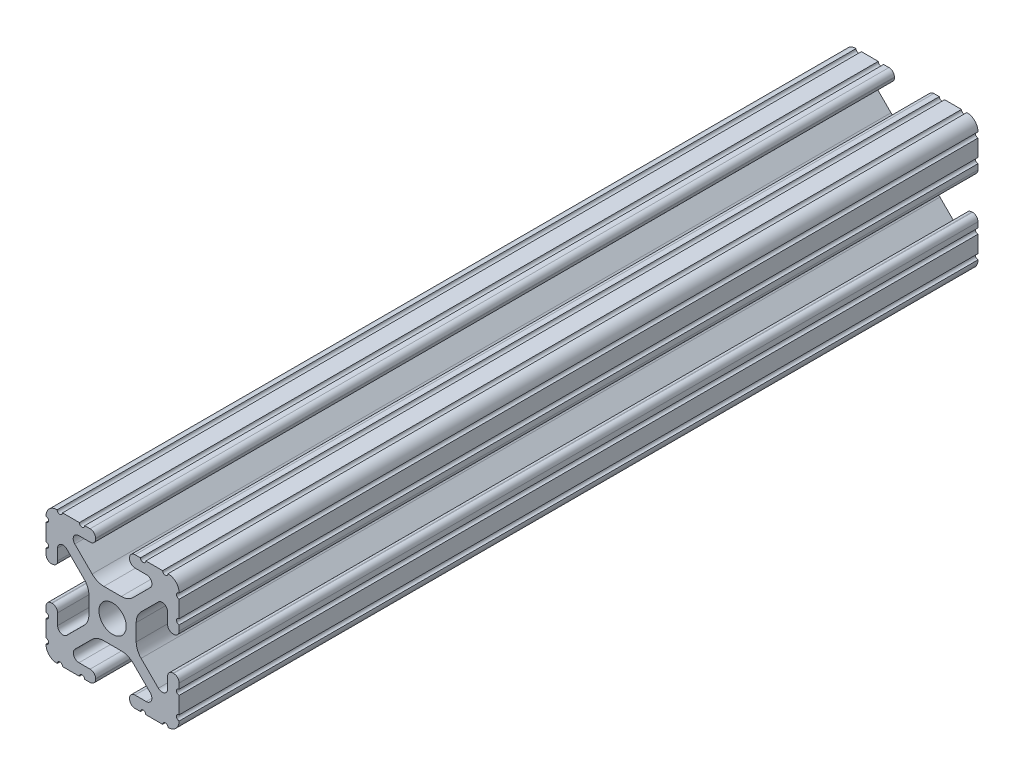
from build123d import *

# Parameters (mm, degrees)
SKETCH1_R           = 2.6035
BOSS_EXTRUDE1_DEPTH = 76.2


with BuildPart() as part:
    # Sketch1 → Boss-Extrude1 (new body, symmetric)
    with BuildSketch(Plane.XY):
        with BuildLine():
            Line((-7.179650497, -8.645192506), (-3.952270251, -5.423690499))
            ThreePointArc((-3.952270251, -5.423690499), (-2.922936451, -4.736929036), (-1.709253557, -4.4958))
            Line((-1.709253557, -4.4958), (1.709253557, -4.4958))
            ThreePointArc((1.709253557, -4.4958), (2.922936451, -4.736929036), (3.952270251, -5.423690499))
            Line((3.952270251, -5.423690499), (7.179650497, -8.645192506))
            ThreePointArc((7.179650497, -8.645192506), (7.41473083, -9.822813117), (6.416408329, -10.4902))
            Line((6.416408329, -10.4902), (4.287512407, -10.4902))
            ThreePointArc((4.287512407, -10.4902), (3.54574862, -10.79744862), (3.2385, -11.539212407))
            Line((3.2385, -11.539212407), (3.2385, -11.650987593))
            ThreePointArc((3.2385, -11.650987593), (3.54574862, -12.39275138), (4.287512407, -12.7))
            Line((4.287512407, -12.7), (5.317126718, -12.7))
            ThreePointArc((5.317126718, -12.7), (5.825126718, -12.192), (6.333126718, -12.7))
            Line((6.333126718, -12.7), (9.550443118, -12.7))
            ThreePointArc((9.550443118, -12.7), (10.058366869, -12.192000006), (10.566443095, -12.699847501))
            ThreePointArc((10.566443095, -12.699847501), (12.082537762, -12.08250727), (12.699846982, -10.566399977))
            ThreePointArc((12.699846982, -10.566399977), (12.192000006, -10.058323491), (12.7, -9.5504))
            Line((12.7, -9.5504), (12.7, -6.3330836))
            ThreePointArc((12.7, -6.3330836), (12.192, -5.8250836), (12.7, -5.3170836))
            Line((12.7, -5.3170836), (12.7, -4.287469289))
            ThreePointArc((12.7, -4.287469289), (12.39275138, -3.545705502), (11.650987593, -3.238456882))
            Line((11.650987593, -3.238456882), (11.539212407, -3.238456882))
            ThreePointArc((11.539212407, -3.238456882), (10.79744862, -3.545705502), (10.4902, -4.287469289))
            Line((10.4902, -4.287469289), (10.4902, -6.402089023))
            ThreePointArc((10.4902, -6.402089023), (9.856505071, -7.351067942), (8.737131347, -7.129408934))
            Line((8.737131347, -7.129408934), (5.441005833, -3.840816462))
            ThreePointArc((5.441005833, -3.840816462), (4.750877967, -2.809883091), (4.5085, -1.593185507))
            Line((4.5085, -1.593185507), (4.5085, 1.593185507))
            ThreePointArc((4.5085, 1.593185507), (4.750877967, 2.809883091), (5.441005833, 3.840816462))
            Line((5.441005833, 3.840816462), (8.737131347, 7.129408934))
            ThreePointArc((8.737131347, 7.129408934), (9.856505071, 7.351067942), (10.4902, 6.402089023))
            Line((10.4902, 6.402089023), (10.4902, 4.287469289))
            ThreePointArc((10.4902, 4.287469289), (10.79744862, 3.545705502), (11.539212407, 3.238456882))
            Line((11.539212407, 3.238456882), (11.650987593, 3.238456882))
            ThreePointArc((11.650987593, 3.238456882), (12.39275138, 3.545705502), (12.7, 4.287469289))
            Line((12.7, 4.287469289), (12.7, 5.3170836))
            ThreePointArc((12.7, 5.3170836), (12.192, 5.8250836), (12.7, 6.3330836))
            Line((12.7, 6.3330836), (12.7, 9.5504))
            ThreePointArc((12.7, 9.5504), (12.192000006, 10.058323491), (12.699846982, 10.566399977))
            ThreePointArc((12.699846982, 10.566399977), (12.082537762, 12.08250727), (10.566443095, 12.699847501))
            ThreePointArc((10.566443095, 12.699847501), (10.058366869, 12.192000006), (9.550443118, 12.7))
            Line((9.550443118, 12.7), (6.333126718, 12.7))
            ThreePointArc((6.333126718, 12.7), (5.825126718, 12.192), (5.317126718, 12.7))
            Line((5.317126718, 12.7), (4.287512407, 12.7))
            ThreePointArc((4.287512407, 12.7), (3.54574862, 12.39275138), (3.2385, 11.650987593))
            Line((3.2385, 11.650987593), (3.2385, 11.539212407))
            ThreePointArc((3.2385, 11.539212407), (3.54574862, 10.79744862), (4.287512407, 10.4902))
            Line((4.287512407, 10.4902), (6.476788598, 10.4902))
            ThreePointArc((6.476788598, 10.4902), (7.432222385, 9.85140422), (7.207036008, 8.724370562))
            Line((7.207036008, 8.724370562), (3.898272566, 5.423169045))
            ThreePointArc((3.898272566, 5.423169045), (2.869120213, 4.736787962), (1.655778399, 4.4958))
            Line((1.655778399, 4.4958), (-1.655778399, 4.4958))
            ThreePointArc((-1.655778399, 4.4958), (-2.869120213, 4.736787962), (-3.898272566, 5.423169045))
            Line((-3.898272566, 5.423169045), (-7.207036008, 8.724370562))
            ThreePointArc((-7.207036008, 8.724370562), (-7.432222385, 9.85140422), (-6.476788598, 10.4902))
            Line((-6.476788598, 10.4902), (-4.287512407, 10.4902))
            ThreePointArc((-4.287512407, 10.4902), (-3.54574862, 10.79744862), (-3.2385, 11.539212407))
            Line((-3.2385, 11.539212407), (-3.2385, 11.650987593))
            ThreePointArc((-3.2385, 11.650987593), (-3.54574862, 12.39275138), (-4.287512407, 12.7))
            Line((-4.287512407, 12.7), (-5.317126718, 12.7))
            ThreePointArc((-5.317126718, 12.7), (-5.825126718, 12.192), (-6.333126718, 12.7))
            Line((-6.333126718, 12.7), (-9.550443118, 12.7))
            ThreePointArc((-9.550443118, 12.7), (-10.058366869, 12.192000006), (-10.566443095, 12.699847501))
            ThreePointArc((-10.566443095, 12.699847501), (-12.082537762, 12.08250727), (-12.699846982, 10.566399977))
            ThreePointArc((-12.699846982, 10.566399977), (-12.192000006, 10.058323491), (-12.7, 9.5504))
            Line((-12.7, 9.5504), (-12.7, 6.3330836))
            ThreePointArc((-12.7, 6.3330836), (-12.192, 5.8250836), (-12.7, 5.3170836))
            Line((-12.7, 5.3170836), (-12.7, 4.287469289))
            ThreePointArc((-12.7, 4.287469289), (-12.39275138, 3.545705502), (-11.650987593, 3.238456882))
            Line((-11.650987593, 3.238456882), (-11.539212407, 3.238456882))
            ThreePointArc((-11.539212407, 3.238456882), (-10.79744862, 3.545705502), (-10.4902, 4.287469289))
            Line((-10.4902, 4.287469289), (-10.4902, 6.402089023))
            ThreePointArc((-10.4902, 6.402089023), (-9.856505071, 7.351067942), (-8.737131347, 7.129408934))
            Line((-8.737131347, 7.129408934), (-5.441005833, 3.840816462))
            ThreePointArc((-5.441005833, 3.840816462), (-4.750877967, 2.809883091), (-4.5085, 1.593185507))
            Line((-4.5085, 1.593185507), (-4.5085, -1.593185507))
            ThreePointArc((-4.5085, -1.593185507), (-4.750877967, -2.809883091), (-5.441005833, -3.840816462))
            Line((-5.441005833, -3.840816462), (-8.737131347, -7.129408934))
            ThreePointArc((-8.737131347, -7.129408934), (-9.856505071, -7.351067942), (-10.4902, -6.402089023))
            Line((-10.4902, -6.402089023), (-10.4902, -4.287469289))
            ThreePointArc((-10.4902, -4.287469289), (-10.79744862, -3.545705502), (-11.539212407, -3.238456882))
            Line((-11.539212407, -3.238456882), (-11.650987593, -3.238456882))
            ThreePointArc((-11.650987593, -3.238456882), (-12.39275138, -3.545705502), (-12.7, -4.287469289))
            Line((-12.7, -4.287469289), (-12.7, -5.3170836))
            ThreePointArc((-12.7, -5.3170836), (-12.192, -5.8250836), (-12.7, -6.3330836))
            Line((-12.7, -6.3330836), (-12.7, -9.5504))
            ThreePointArc((-12.7, -9.5504), (-12.192000006, -10.058323491), (-12.699846982, -10.566399977))
            ThreePointArc((-12.699846982, -10.566399977), (-12.082537762, -12.08250727), (-10.566443095, -12.699847501))
            ThreePointArc((-10.566443095, -12.699847501), (-10.058366869, -12.192000006), (-9.550443118, -12.7))
            Line((-9.550443118, -12.7), (-6.333126718, -12.7))
            ThreePointArc((-6.333126718, -12.7), (-5.825126718, -12.192), (-5.317126718, -12.7))
            Line((-5.317126718, -12.7), (-4.287512407, -12.7))
            ThreePointArc((-4.287512407, -12.7), (-3.54574862, -12.39275138), (-3.2385, -11.650987593))
            Line((-3.2385, -11.650987593), (-3.2385, -11.539212407))
            ThreePointArc((-3.2385, -11.539212407), (-3.54574862, -10.79744862), (-4.287512407, -10.4902))
            Line((-4.287512407, -10.4902), (-6.416408329, -10.4902))
            ThreePointArc((-6.416408329, -10.4902), (-7.41473083, -9.822813117), (-7.179650497, -8.645192506))
        make_face()
        Circle(SKETCH1_R, mode=Mode.SUBTRACT)
    extrude(amount=BOSS_EXTRUDE1_DEPTH, both=True)


solid = part.part
